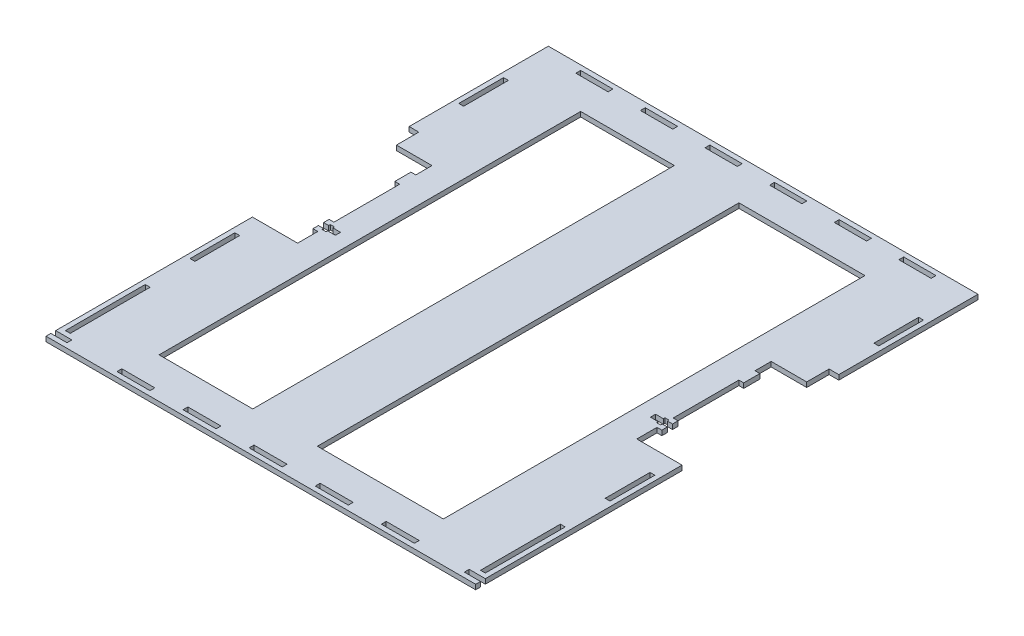
from build123d import *

# Parameters (mm, degrees)
SKETCH1_W           = 3
SKETCH1_H           = 49.4545
SKETCH1_W_2         = 20.4615
SKETCH1_H_2         = 3
SKETCH1_H_3         = 27.7273
SKETCH1_W_3         = 20
SKETCH1_W_4         = 176
SKETCH1_H_4         = 261
BOSS_EXTRUDE1_DEPTH = 3
SKETCH2_W           = 10.5
SKETCH2_H           = 3.2
SKETCH2_W_2         = 2.5
SKETCH2_H_2         = 5.2
CUT_EXTRUDE1_DEPTH  = 10
SKETCH4_W           = 40
SKETCH4_H           = 261
BOSS_EXTRUDE2_DEPTH = 3


with BuildPart() as part:
    # Sketch1 → Boss-Extrude1 (new body)
    with BuildSketch(Plane(origin=(0, 0, 0), x_dir=(1, 0, 0), z_dir=(0, 1, 0))):
        Polygon((-133, -152.5), (-133, -155.5), (133, -155.5), (133, -152.5), (123, -152.5), (123, -149.5), (133, -149.5), (133, -27.7273), (105, -27.7273), (105, -15.2273), (108, -15.2273), (108, -5.2273), (105, -5.2273), (105, 35.4545), (108, 35.4545), (108, 45.4545), (105, 45.4545), (105, 55.4545), (127, 55.4545), (127, 69.3181), (133, 69.3181), (133, 155.5), (-133, 155.5), (-133, 69.3181), (-127, 69.3181), (-127, 55.4545), (-105, 55.4545), (-105, 45.4545), (-108, 45.4545), (-108, 35.4545), (-105, 35.4545), (-105, -5.2273), (-108, -5.2273), (-108, -15.2273), (-105, -15.2273), (-105, -27.7273), (-133, -27.7273), (-133, -149.5), (-123, -149.5), (-123, -152.5), align=None)
        with Locations((-128.5, -121.77275)):
            Rectangle(SKETCH1_W, SKETCH1_H, mode=Mode.SUBTRACT)
        with Locations((-81.846, -151)):
            Rectangle(SKETCH1_W_2, SKETCH1_H_2, mode=Mode.SUBTRACT)
        with Locations((-40.923, -151)):
            Rectangle(SKETCH1_W_2, SKETCH1_H_2, mode=Mode.SUBTRACT)
        with Locations((0, -151)):
            Rectangle(SKETCH1_W_2, SKETCH1_H_2, mode=Mode.SUBTRACT)
        with Locations((-128.5, -55.45455)):
            Rectangle(SKETCH1_W, SKETCH1_H_3, mode=Mode.SUBTRACT)
        with Locations((40.923, -151)):
            Rectangle(SKETCH1_W_2, SKETCH1_H_2, mode=Mode.SUBTRACT)
        with Locations((81.846, -151)):
            Rectangle(SKETCH1_W_2, SKETCH1_H_2, mode=Mode.SUBTRACT)
        with Locations((128.5, -121.77275)):
            Rectangle(SKETCH1_W, SKETCH1_H, mode=Mode.SUBTRACT)
        with Locations((128.5, -55.45455)):
            Rectangle(SKETCH1_W, SKETCH1_H_3, mode=Mode.SUBTRACT)
        with Locations((-128.5, 110.90905)):
            Rectangle(SKETCH1_W, SKETCH1_H_3, mode=Mode.SUBTRACT)
        with Locations((-100, 151)):
            Rectangle(SKETCH1_W_3, SKETCH1_H_2, mode=Mode.SUBTRACT)
        with Locations((-60, 151)):
            Rectangle(SKETCH1_W_3, SKETCH1_H_2, mode=Mode.SUBTRACT)
        with Locations((-20, 151)):
            Rectangle(SKETCH1_W_3, SKETCH1_H_2, mode=Mode.SUBTRACT)
        Rectangle(SKETCH1_W_4, SKETCH1_H_4, mode=Mode.SUBTRACT)
        with Locations((20, 151)):
            Rectangle(SKETCH1_W_3, SKETCH1_H_2, mode=Mode.SUBTRACT)
        with Locations((60, 151)):
            Rectangle(SKETCH1_W_3, SKETCH1_H_2, mode=Mode.SUBTRACT)
        with Locations((128.5, 110.90905)):
            Rectangle(SKETCH1_W, SKETCH1_H_3, mode=Mode.SUBTRACT)
        with Locations((100, 151)):
            Rectangle(SKETCH1_W_3, SKETCH1_H_2, mode=Mode.SUBTRACT)
    extrude(amount=BOSS_EXTRUDE1_DEPTH)

    # Sketch2 → Cut-Extrude1 (cut)
    with BuildSketch(Plane(origin=(0, 3, 0), x_dir=(1, 0, 0), z_dir=(0, 1, 0))):
        with Locations((-102.75, -10.2273)):
            Rectangle(SKETCH2_W, SKETCH2_H)
        with Locations((102.75, -10.2273)):
            Rectangle(SKETCH2_W, SKETCH2_H)
        with Locations((103.575, -10.2273)):
            Rectangle(SKETCH2_W_2, SKETCH2_H_2)
        with Locations((-103.575, -10.2273)):
            Rectangle(SKETCH2_W_2, SKETCH2_H_2)
    extrude(amount=-CUT_EXTRUDE1_DEPTH, mode=Mode.SUBTRACT)

    # Sketch4 → Boss-Extrude2 (add)
    with BuildSketch(Plane(origin=(0, 0, 0), x_dir=(1, 0, 0), z_dir=(0, 1, 0))):
        with Locations((-10, 0)):
            Rectangle(SKETCH4_W, SKETCH4_H)
    extrude(amount=BOSS_EXTRUDE2_DEPTH)


solid = part.part
